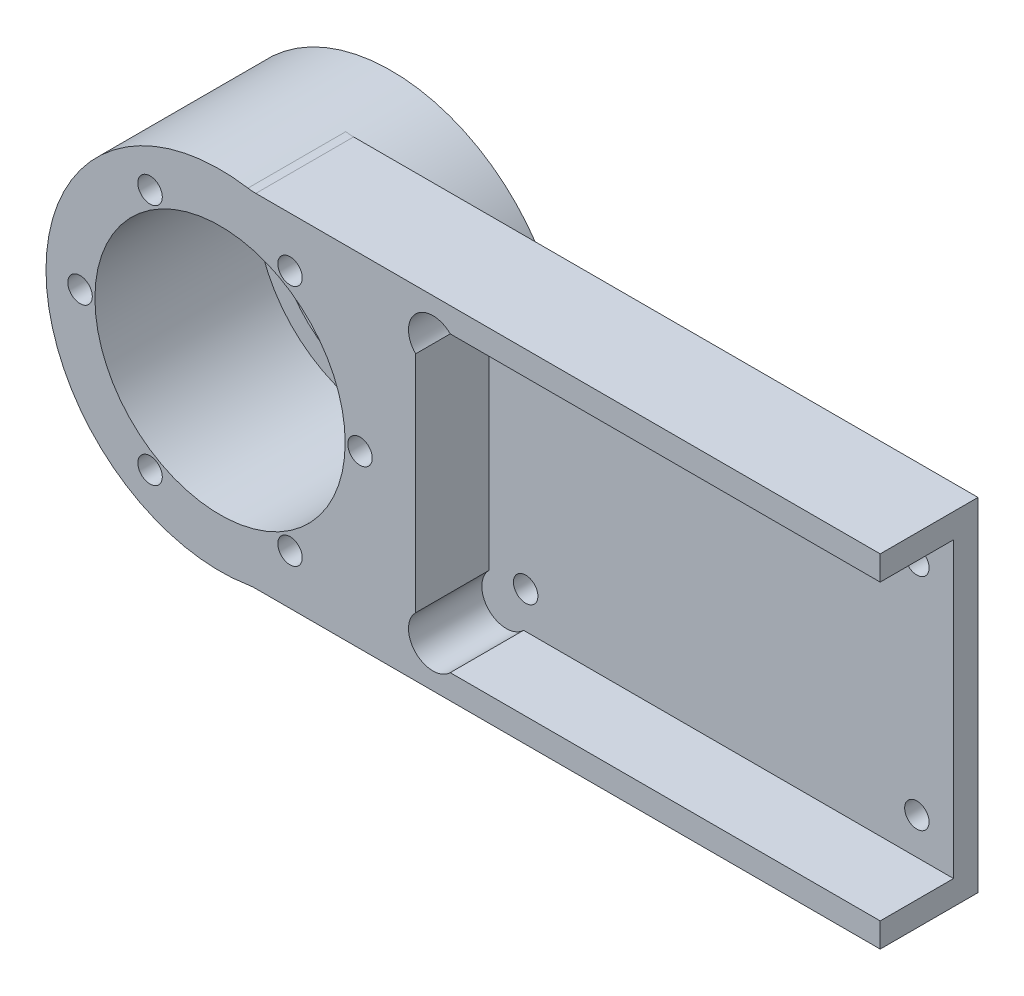
from build123d import *

# Parameters (mm, degrees)
SKETCH1_R               = 32.5
SKETCH1_W               = 120.65
SKETCH1_H               = 76.2
BOSS_EXTRUDE2_DEPTH     = 6.35
BOSS_EXTRUDE3_START     = 6.35
SKETCH1_3_R             = 32.5
BOSS_EXTRUDE3_DEPTH     = 19.05
SKETCH2_R               = 3.175
CUT_EXTRUDE1_DEPTH      = 20.05
CUT_EXTRUDE1_DEPTH_BACK = 7.35
SKETCH3_R               = 6.35
CUT_EXTRUDE2_DEPTH      = 19.05
FILLET1_R               = 12.7
SKETCH5_R               = 32.5
BOSS_EXTRUDE6_DEPTH     = 19.05
SKETCH6_R               = 32.5
SKETCH6_R_2             = 27.5
BOSS_EXTRUDE7_DEPTH     = 2.54
SKETCH9_R               = 3.175
CUT_EXTRUDE3_DEPTH      = 1
CUT_EXTRUDE3_DEPTH_BACK = 45.45


with BuildPart() as part:
    # Sketch1 → Boss-Extrude2 (new body)
    with BuildSketch(Plane.XY):
        with BuildLine():
            Line((8.199848, 44.45), (171.45, 44.45))
            Line((171.45, 44.45), (171.45, 38.1))
            Line((171.45, 38.1), (50.8, 38.1))
            Line((50.8, 38.1), (50.8, -38.1))
            Line((50.8, -38.1), (171.45, -38.1))
            Line((171.45, -38.1), (171.45, -44.45))
            Line((171.45, -44.45), (8.199848, -44.45))
            ThreePointArc((8.199848, -44.45), (-45.2, 0), (8.199848, 44.45))
        make_face()
        Circle(SKETCH1_R, mode=Mode.SUBTRACT)
        with Locations((111.125, 0)):
            Rectangle(SKETCH1_W, SKETCH1_H)
    extrude(amount=BOSS_EXTRUDE2_DEPTH)

    # Sketch1_3 → Boss-Extrude3 (add)
    with BuildSketch(Plane.XY.offset(BOSS_EXTRUDE3_START)):
        with BuildLine():
            Line((8.199848, 44.45), (171.45, 44.45))
            Line((171.45, 44.45), (171.45, 38.1))
            Line((171.45, 38.1), (50.8, 38.1))
            Line((50.8, 38.1), (50.8, -38.1))
            Line((50.8, -38.1), (171.45, -38.1))
            Line((171.45, -38.1), (171.45, -44.45))
            Line((171.45, -44.45), (8.199848, -44.45))
            ThreePointArc((8.199848, -44.45), (-45.2, 0), (8.199848, 44.45))
        make_face()
        Circle(SKETCH1_3_R, mode=Mode.SUBTRACT)
    extrude(amount=BOSS_EXTRUDE3_DEPTH)

    # Sketch2 → Cut-Extrude1 (cut, two sides)
    with BuildSketch(Plane.XY.offset(6.35)) as cut_extrude1_sk:
        with Locations((60.325, 28.575)):
            Circle(SKETCH2_R)
        with Locations((161.925, 28.575)):
            Circle(SKETCH2_R)
        with Locations((161.925, -28.575)):
            Circle(SKETCH2_R)
        with Locations((60.325, -28.575)):
            Circle(SKETCH2_R)
    extrude(amount=CUT_EXTRUDE1_DEPTH, mode=Mode.SUBTRACT)
    extrude(cut_extrude1_sk.sketch, amount=-CUT_EXTRUDE1_DEPTH_BACK, mode=Mode.SUBTRACT)

    # Sketch3 → Cut-Extrude2 (cut)
    with BuildSketch(Plane.XY.offset(25.4)):
        with Locations((55.290128, 33.609872)):
            Circle(SKETCH3_R)
        with Locations((55.290128, -33.609872)):
            Circle(SKETCH3_R)
    extrude(amount=-CUT_EXTRUDE2_DEPTH, mode=Mode.SUBTRACT)

    # Fillet1
    fillet1_edges = [part.edges().sort_by_distance(p)[0] for p in [
        (8.199848, -44.45, 12.7),
        (8.199848, 44.45, 12.7),
    ]]
    fillet(fillet1_edges, radius=FILLET1_R)

    # Sketch5 → Boss-Extrude6 (add)
    with BuildSketch(Plane(origin=(0, 0, 0), x_dir=(-1, 0, 0), z_dir=(0, 0, -1))):
        with BuildLine():
            ThreePointArc((-7.2516, -44.614508), (45.2, 0), (-7.2516, 44.614508))
            ThreePointArc((-7.2516, 44.614508), (-45.2, 0), (-7.2516, -44.614508))
        make_face()
        Circle(SKETCH5_R, mode=Mode.SUBTRACT)
    extrude(amount=BOSS_EXTRUDE6_DEPTH)

    # Sketch6 → Boss-Extrude7 (add)
    with BuildSketch(Plane(origin=(0, 0, -19.05), x_dir=(-1, 0, 0), z_dir=(0, 0, -1))):
        Circle(SKETCH6_R)
        Circle(SKETCH6_R_2, mode=Mode.SUBTRACT)
    extrude(amount=-BOSS_EXTRUDE7_DEPTH)

    # Sketch9 → Cut-Extrude3 (cut, two sides)
    with BuildSketch(Plane(origin=(0, 0, -19.05), x_dir=(-1, 0, 0), z_dir=(0, 0, -1))) as cut_extrude3_sk:
        with Locations((36.35, 0)):
            Circle(SKETCH9_R)
        with Locations((18.175, -31.480023)):
            Circle(SKETCH9_R)
        with Locations((-18.175, -31.480023)):
            Circle(SKETCH9_R)
        with Locations((-36.35, 0)):
            Circle(SKETCH9_R)
        with Locations((-18.175, 31.480023)):
            Circle(SKETCH9_R)
        with Locations((18.175, 31.480023)):
            Circle(SKETCH9_R)
    extrude(amount=CUT_EXTRUDE3_DEPTH, mode=Mode.SUBTRACT)
    extrude(cut_extrude3_sk.sketch, amount=-CUT_EXTRUDE3_DEPTH_BACK, mode=Mode.SUBTRACT)


solid = part.part
